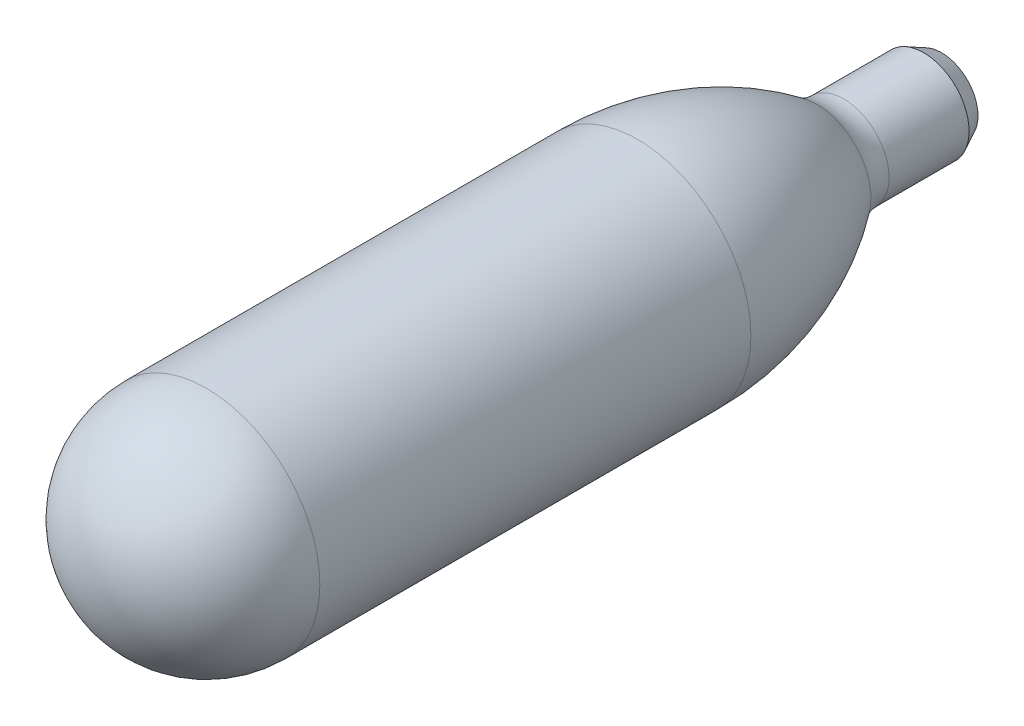
from build123d import *

# Parameters (mm, degrees)
CHAMFER1_SIZE      = 1
CHAMFER1_SIZE2     = 2
SHELL1_T           = 1.25
SKETCH3_R          = 3.318
CUT_EXTRUDE1_DEPTH = 2.54


with BuildPart() as part:
    # Sketch1 → Revolve1 (revolve)
    with BuildSketch(Plane(origin=(0, 0, 0), x_dir=(0, 0, -1), z_dir=(1, 0, 0))):
        with BuildLine():
            Line((0, 0), (95, 0))
            Line((95, 0), (95, 5.08))
            Line((95, 5.08), (84.042781462, 5.08))
            ThreePointArc((84.042781462, 5.08), (82.450318528, 5.336053296), (81.018389209, 6.078400864))
            ThreePointArc((81.018389209, 6.078400864), (71.521540522, 11.001802069), (60.96, 12.7))
            Line((60.96, 12.7), (12.7, 12.7))
            ThreePointArc((12.7, 12.7), (3.719743879, 8.980256121), (0, 0))
        make_face()
    revolve(axis=Axis((0, 0, 0), (0, 0, -1)))

    # Chamfer1
    chamfer1_edges = [part.edges().sort_by_distance(p)[0] for p in [
        (0, -5.08, -95),
    ]]
    chamfer1_side = [part.faces().sort_by_distance(p)[0] for p in [
        (0, 0, -95),
    ]]
    chamfer(chamfer1_edges, length=CHAMFER1_SIZE, length2=CHAMFER1_SIZE2, reference=chamfer1_side[0])

    # Shell1 (no face opened: a closed hollow body)
    add(offset(amount=-SHELL1_T, mode=Mode.PRIVATE), mode=Mode.SUBTRACT)

    # Sketch3 → Cut-Extrude1 (cut)
    with BuildSketch(Plane(origin=(0, 0, -95), x_dir=(-1, 0, 0), z_dir=(0, 0, -1))):
        Circle(SKETCH3_R)
    extrude(amount=-CUT_EXTRUDE1_DEPTH, mode=Mode.SUBTRACT)


solid = part.part
